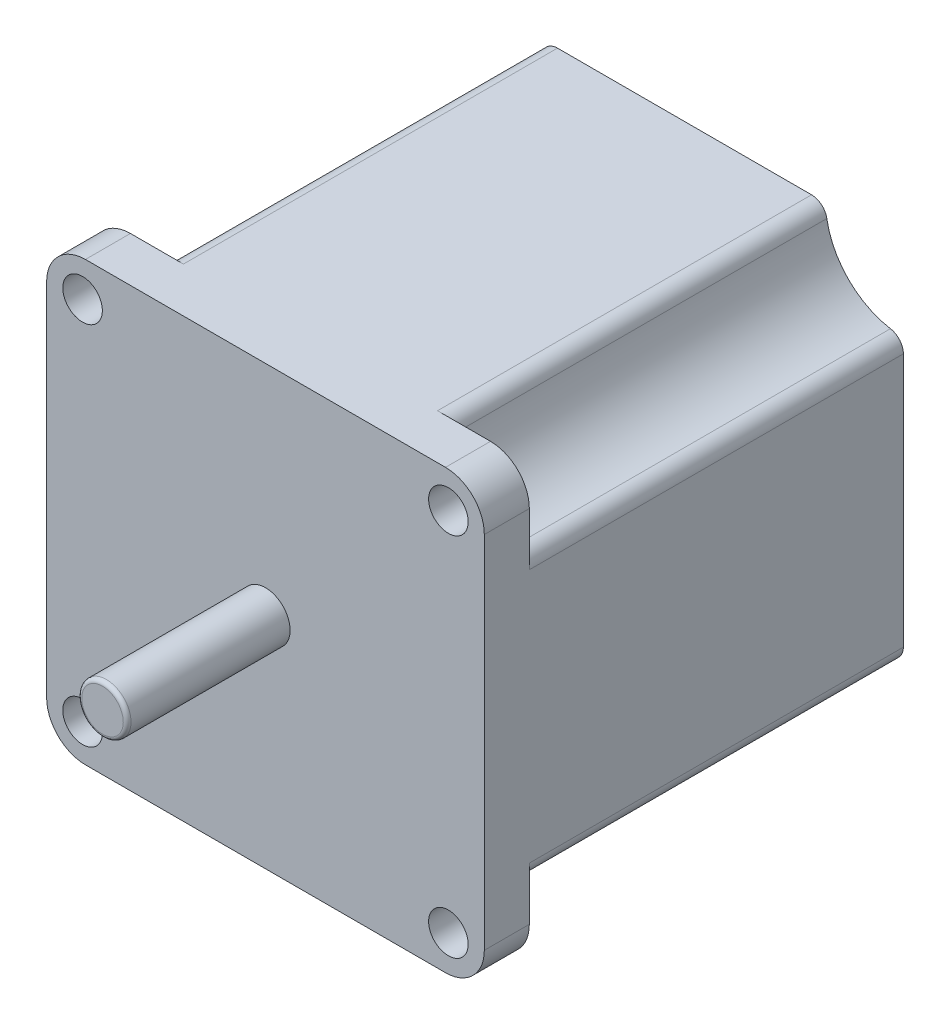
from build123d import *

# Parameters (mm, degrees)
ESQUISSE2_W             = 56.4
ESQUISSE2_H             = 56.4
BOSS_EXTRU_2_DEPTH      = 54
ESQUISSE3_R             = 2.55
ENL_V_MAT_EXTRU_1_DEPTH = 54
CONG_2_R                = 5
CONG_3_R                = 5
CONG_4_R                = 5
CONG_6_R                = 5
ESQUISSE4_R             = 2.55
ENL_V_MAT_EXTRU_2_DEPTH = 48.2
CONG_7_R                = 2
CONG_8_R                = 2
CONG_9_R                = 2
CONG_10_R               = 2
CONG_11_R               = 2
CONG_12_R               = 2
CONG_13_R               = 2
CONG_14_R               = 2
ESQUISSE5_R             = 3.175
BOSS_EXTRU_3_DEPTH      = 21
CONG_15_R               = 0.5


with BuildPart() as part:
    # Esquisse2 → Boss.-Extru.2 (new body)
    with BuildSketch(Plane.XY):
        Rectangle(ESQUISSE2_W, ESQUISSE2_H)
    extrude(amount=BOSS_EXTRU_2_DEPTH)

    # Esquisse3 → Enlèv. mat.-Extru.1 (cut)
    with BuildSketch(Plane.XY.offset(54)):
        with Locations((-23.57, 23.57)):
            Circle(ESQUISSE3_R)
        with Locations((23.57, 23.57)):
            Circle(ESQUISSE3_R)
        with Locations((23.57, -23.57)):
            Circle(ESQUISSE3_R)
        with Locations((-23.57, -23.57)):
            Circle(ESQUISSE3_R)
    extrude(amount=-ENL_V_MAT_EXTRU_1_DEPTH, mode=Mode.SUBTRACT)

    # Congé2
    cong_2_edges = [part.edges().sort_by_distance(p)[0] for p in [
        (28.2, 28.2, 27),
    ]]
    fillet(cong_2_edges, radius=CONG_2_R)

    # Congé3
    cong_3_edges = [part.edges().sort_by_distance(p)[0] for p in [
        (28.2, -28.2, 27),
    ]]
    fillet(cong_3_edges, radius=CONG_3_R)

    # Congé4
    cong_4_edges = [part.edges().sort_by_distance(p)[0] for p in [
        (-28.2, 28.2, 27),
    ]]
    fillet(cong_4_edges, radius=CONG_4_R)

    # Congé6
    cong_6_edges = [part.edges().sort_by_distance(p)[0] for p in [
        (-28.2, -28.2, 27),
    ]]
    fillet(cong_6_edges, radius=CONG_6_R)

    # Esquisse4 → Enlèv. mat.-Extru.2 (cut)
    with BuildSketch(Plane(origin=(0, 0, 0), x_dir=(-1, 0, 0), z_dir=(0, 0, -1))):
        with BuildLine():
            ThreePointArc((-18.2, -28.2), (-21.128932188, -21.128932188), (-28.2, -18.2))
            Line((-28.2, -18.2), (-28.2, -23.2))
            ThreePointArc((-28.2, -23.2), (-26.735533906, -26.735533906), (-23.2, -28.2))
            Line((-23.2, -28.2), (-18.2, -28.2))
        make_face()
        with Locations((-23.57, -23.57)):
            Circle(ESQUISSE4_R, mode=Mode.SUBTRACT)
        with BuildLine():
            Line((-28.2, 28.2), (-18.2, 28.2))
            ThreePointArc((-18.2, 28.2), (-21.128932188, 21.128932188), (-28.2, 18.2))
            Line((-28.2, 18.2), (-28.2, 28.2))
        make_face()
        with BuildLine():
            ThreePointArc((28.2, -18.2), (21.128932188, -21.128932188), (18.2, -28.2))
            Line((18.2, -28.2), (28.2, -28.2))
            Line((28.2, -28.2), (28.2, -18.2))
        make_face()
        with BuildLine():
            ThreePointArc((18.2, 28.2), (21.128932188, 21.128932188), (28.2, 18.2))
            Line((28.2, 18.2), (28.2, 28.2))
            Line((28.2, 28.2), (18.2, 28.2))
        make_face()
    extrude(amount=-ENL_V_MAT_EXTRU_2_DEPTH, mode=Mode.SUBTRACT)

    # Congé7
    cong_7_edges = [part.edges().sort_by_distance(p)[0] for p in [
        (18.2, 28.2, 24.1),
    ]]
    fillet(cong_7_edges, radius=CONG_7_R)

    # Congé8
    cong_8_edges = [part.edges().sort_by_distance(p)[0] for p in [
        (28.2, 18.2, 24.1),
    ]]
    fillet(cong_8_edges, radius=CONG_8_R)

    # Congé9
    cong_9_edges = [part.edges().sort_by_distance(p)[0] for p in [
        (-18.2, 28.2, 24.1),
    ]]
    fillet(cong_9_edges, radius=CONG_9_R)

    # Congé10
    cong_10_edges = [part.edges().sort_by_distance(p)[0] for p in [
        (-28.2, 18.2, 24.1),
    ]]
    fillet(cong_10_edges, radius=CONG_10_R)

    # Congé11
    cong_11_edges = [part.edges().sort_by_distance(p)[0] for p in [
        (-28.2, -18.2, 24.1),
    ]]
    fillet(cong_11_edges, radius=CONG_11_R)

    # Congé12
    cong_12_edges = [part.edges().sort_by_distance(p)[0] for p in [
        (-18.2, -28.2, 24.1),
    ]]
    fillet(cong_12_edges, radius=CONG_12_R)

    # Congé13
    cong_13_edges = [part.edges().sort_by_distance(p)[0] for p in [
        (18.2, -28.2, 24.1),
    ]]
    fillet(cong_13_edges, radius=CONG_13_R)

    # Congé14
    cong_14_edges = [part.edges().sort_by_distance(p)[0] for p in [
        (28.2, -18.2, 24.1),
    ]]
    fillet(cong_14_edges, radius=CONG_14_R)

    # Esquisse5 → Boss.-Extru.3 (add)
    with BuildSketch(Plane.XY.offset(54)):
        Circle(ESQUISSE5_R)
    extrude(amount=BOSS_EXTRU_3_DEPTH)

    # Congé15
    cong_15_edges = [part.edges().sort_by_distance(p)[0] for p in [
        (-3.175, 0, 75),
    ]]
    fillet(cong_15_edges, radius=CONG_15_R)


solid = part.part
